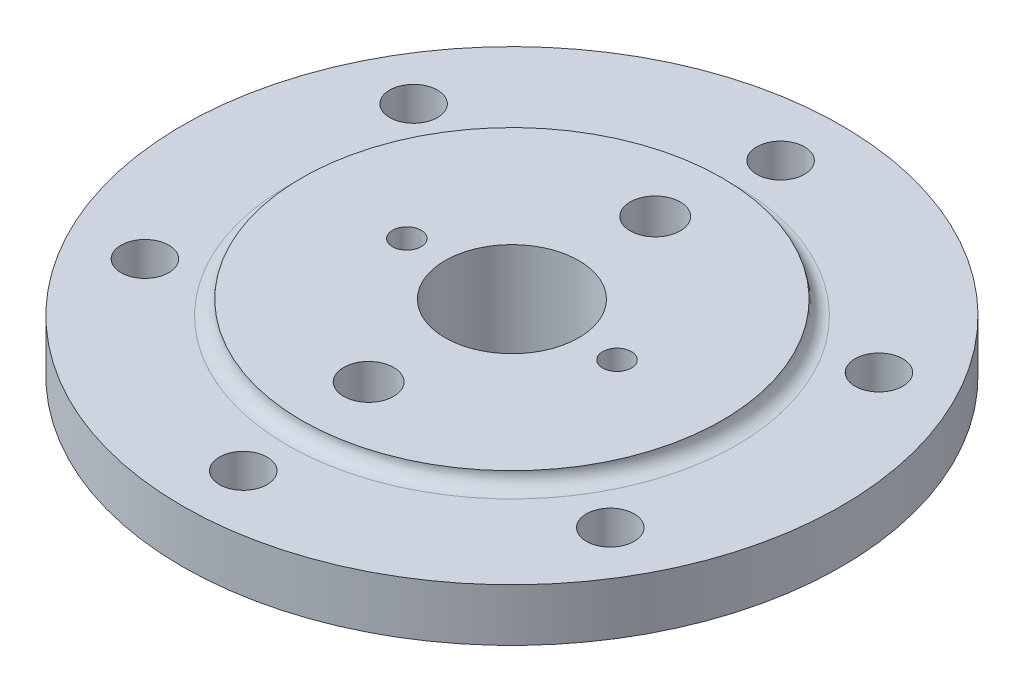
from build123d import *

# Parameters (mm, degrees)
SKETCH4_R              = 10
CUT_EXTRUDE1_DEPTH     = 76
M24_TAPPED_HOLE1_D     = 21
M24_TAPPED_HOLE1_DEPTH = 27
M24_TAPPED_HOLE1_TIP   = 6.062177826
M12_TAPPED_HOLE1_D     = 12
M12_TAPPED_HOLE1_DEPTH = 15
M12_TAPPED_HOLE1_TIP   = 3.464101615


with BuildPart() as part:
    # Sketch2 → Revolve1 (revolve)
    with BuildSketch(Plane(origin=(0, 0, 0), x_dir=(0, 0, -1), z_dir=(1, 0, 0))):
        with BuildLine():
            Line((28, 0), (88, 0))
            ThreePointArc((88, 0), (89.757359313, -4.242640687), (94, -6))
            Line((94, -6), (138, -6))
            Line((138, -6), (138, -28))
            Line((138, -28), (81, -28))
            Line((81, -28), (81, -34))
            Line((81, -34), (35, -81))
            Line((35, -81), (14, -81))
            Line((14, -81), (14, -50))
            Line((14, -50), (28, -41.917096231))
            Line((28, -41.917096231), (28, 0))
        make_face()
    revolve(axis=Axis((0, 70.454304255, 0), (0, -1, 0)))

    # Sketch4 → Cut-Extrude1 (cut, through all)
    with BuildSketch(Plane(origin=(0, -6, 0), x_dir=(1, 0, 0), z_dir=(0, 1, 0))):
        with Locations((0, 112.5)):
            Circle(SKETCH4_R)
        with Locations((97.427857926, 56.25)):
            Circle(SKETCH4_R)
        with Locations((97.427857926, -56.25)):
            Circle(SKETCH4_R)
        with Locations((0, -112.5)):
            Circle(SKETCH4_R)
        with Locations((-97.427857926, -56.25)):
            Circle(SKETCH4_R)
        with Locations((-97.427857926, 56.25)):
            Circle(SKETCH4_R)
    extrude(amount=-CUT_EXTRUDE1_DEPTH, mode=Mode.SUBTRACT)

    # M24 Tapped Hole1
    with Locations(Plane(origin=(0, 0, 0), x_dir=(1, 0, 0), z_dir=(0, 1, 0))):
        with Locations((0, -60), (0, 60)):
            Hole(M24_TAPPED_HOLE1_D / 2, depth=M24_TAPPED_HOLE1_DEPTH)
            with Locations((0, 0, -(M24_TAPPED_HOLE1_DEPTH + M24_TAPPED_HOLE1_TIP / 2))):  # 120° drill point
                Cone(0, M24_TAPPED_HOLE1_D / 2, M24_TAPPED_HOLE1_TIP, mode=Mode.SUBTRACT)

    # M12 Tapped Hole1
    with Locations(Plane(origin=(0, 0, 0), x_dir=(1, 0, 0), z_dir=(0, 1, 0))):
        with Locations((-44, 0), (44, 0)):
            Hole(M12_TAPPED_HOLE1_D / 2, depth=M12_TAPPED_HOLE1_DEPTH)
            with Locations((0, 0, -(M12_TAPPED_HOLE1_DEPTH + M12_TAPPED_HOLE1_TIP / 2))):  # 120° drill point
                Cone(0, M12_TAPPED_HOLE1_D / 2, M12_TAPPED_HOLE1_TIP, mode=Mode.SUBTRACT)


solid = part.part
